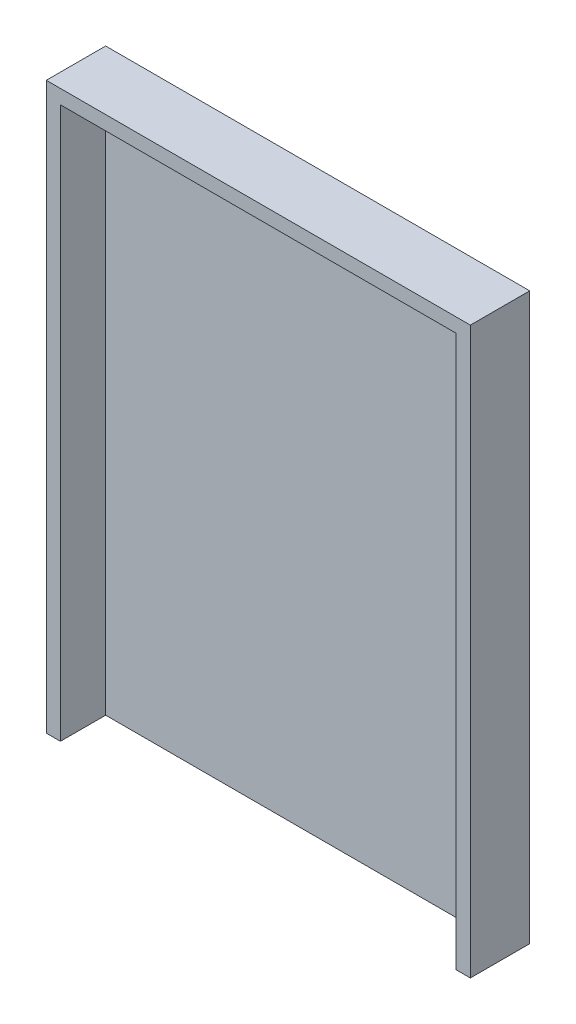
from build123d import *

# Parameters (mm, degrees)
SKETCH_1_W      = 300
SKETCH_1_H      = 400
EXTRUDE_1_DEPTH = 10
EXTRUDE_2_DEPTH = 32


with BuildPart() as part:
    # 草图1 → 凸台-拉伸1 (new body)
    with BuildSketch(Plane.XY):
        with Locations((115.046975242, -172.111948332)):
            Rectangle(SKETCH_1_W, SKETCH_1_H)
    extrude(amount=EXTRUDE_1_DEPTH)

    # 草图2 → 凸台-拉伸2 (add)
    with BuildSketch(Plane.XY.offset(10)):
        Polygon((265.046975242, -372.111948332), (265.046975242, 27.888051668), (-34.953024758, 27.888051668), (-34.953024758, -372.111948332), (-24.953024758, -372.111948332), (-24.953024758, 17.888051668), (255.046975242, 17.888051668), (255.046975242, -372.111948332), align=None)
    extrude(amount=EXTRUDE_2_DEPTH)


solid = part.part
